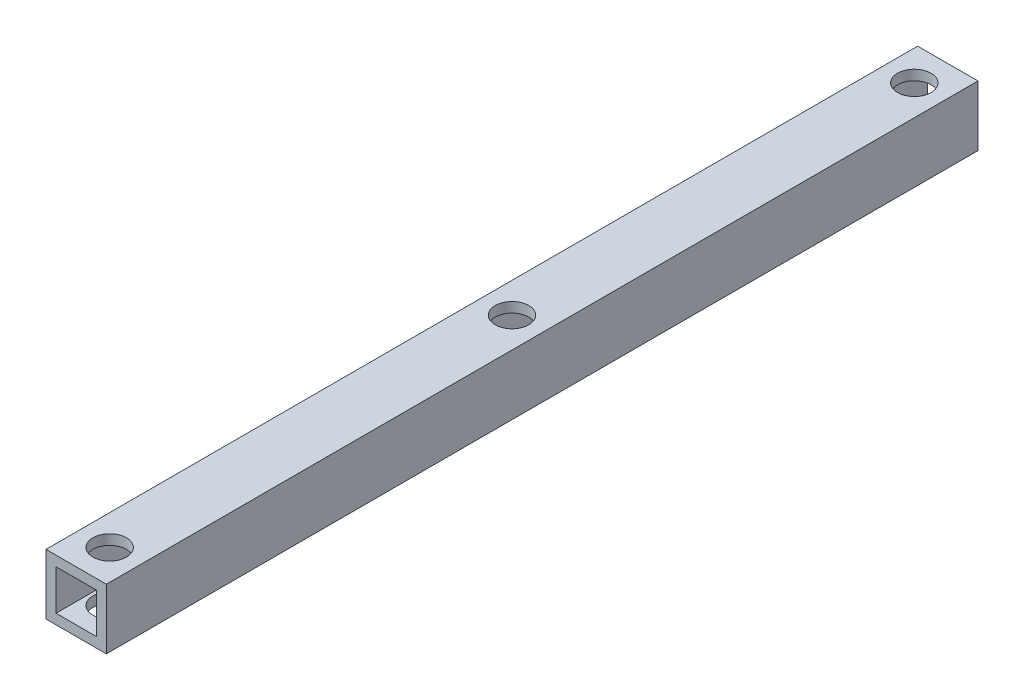
from build123d import *

# Parameters (mm, degrees)
SKETCH_1_W          = 9
SKETCH_1_H          = 9
SKETCH_1_W_2        = 6
SKETCH_1_H_2        = 6
EXTRUDE_1_DEPTH     = 130
SKETCH_2_R          = 2.5
CUT_EXTRUDE_1_DEPTH = 90


with BuildPart() as part:
    # ｽｹｯﾁ1 → ﾎﾞｽ - 押し出し1 (new body)
    with BuildSketch(Plane.XY):
        Rectangle(SKETCH_1_W, SKETCH_1_H)
        Rectangle(SKETCH_1_W_2, SKETCH_1_H_2, mode=Mode.SUBTRACT)
    extrude(amount=EXTRUDE_1_DEPTH)

    # ｽｹｯﾁ2 → ｶｯﾄ - 押し出し1 (cut)
    with BuildSketch(Plane(origin=(0, 4.5, 0), x_dir=(1, 0, 0), z_dir=(0, 1, 0))):
        with Locations((0, -65)):
            Circle(SKETCH_2_R)
        with Locations((0, -5)):
            Circle(SKETCH_2_R)
        with Locations((0, -125)):
            Circle(SKETCH_2_R)
    extrude(amount=-CUT_EXTRUDE_1_DEPTH, mode=Mode.SUBTRACT)


solid = part.part
